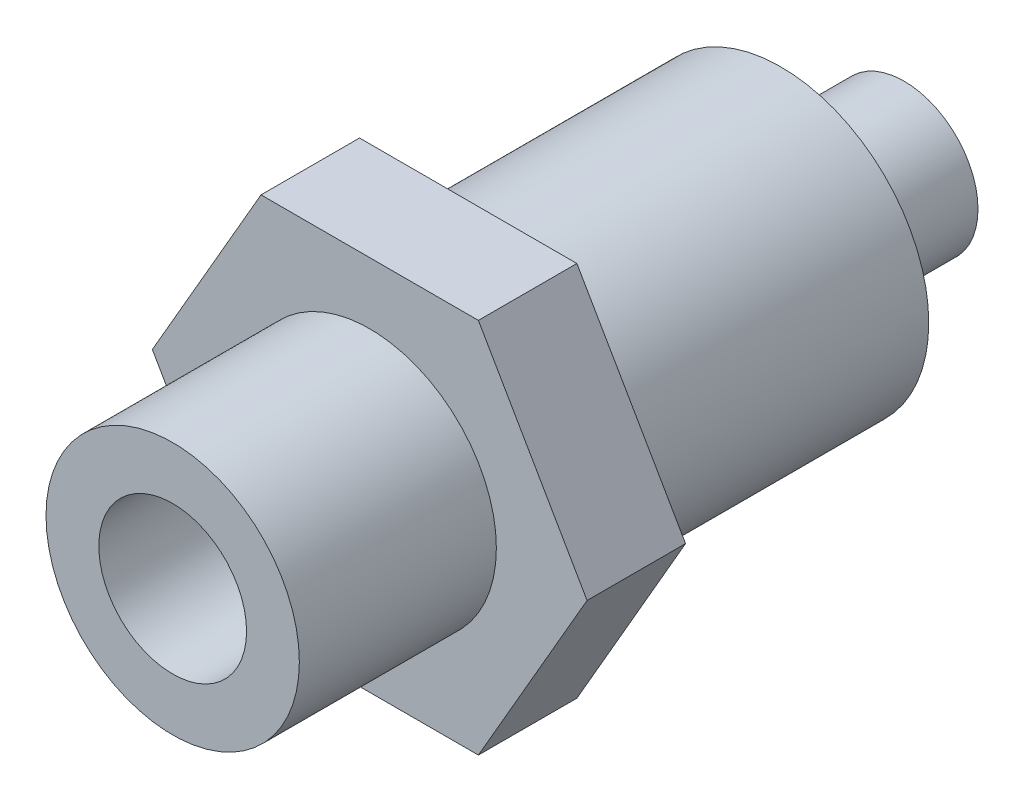
from build123d import *

# Parameters (mm, degrees)
SKETCH1_R           = 5.1435
SKETCH1_R_2         = 3
BOSS_EXTRUDE1_DEPTH = 8
SKETCH1_3_R         = 5.1435
BOSS_EXTRUDE2_DEPTH = 4
BOSS_EXTRUDE3_START = -4
SKETCH1_5_R         = 6
SKETCH1_5_R_2       = 5.1435
SKETCH1_5_R_3       = 3
BOSS_EXTRUDE3_DEPTH = 12.7
BOSS_EXTRUDE4_START = -16.7
SKETCH1_7_R         = 3
BOSS_EXTRUDE4_DEPTH = 5


with BuildPart() as part:
    # Sketch1 → Boss-Extrude1 (new body)
    with BuildSketch(Plane.XY):
        Circle(SKETCH1_R)
        Circle(SKETCH1_R_2, mode=Mode.SUBTRACT)
    extrude(amount=BOSS_EXTRUDE1_DEPTH)


with BuildPart() as body_2:
    # Sketch1_3 → Boss-Extrude2 (new body)
    with BuildSketch(Plane.XY):
        Polygon((8.825953565, 0), (4.412976783, 7.6435), (-4.412976783, 7.6435), (-8.825953565, 0), (-4.412976783, -7.6435), (4.412976783, -7.6435), align=None)
        Circle(SKETCH1_3_R, mode=Mode.SUBTRACT)
    extrude(amount=-BOSS_EXTRUDE2_DEPTH)

    # Sketch1_5 → Boss-Extrude3 (add)
    with BuildSketch(Plane.XY.offset(BOSS_EXTRUDE3_START)):
        Circle(SKETCH1_5_R)
        Circle(SKETCH1_5_R_2, mode=Mode.SUBTRACT)
        Circle(SKETCH1_5_R_2)
        Circle(SKETCH1_5_R_3, mode=Mode.SUBTRACT)
        Circle(SKETCH1_5_R_3)
    extrude(amount=-BOSS_EXTRUDE3_DEPTH)

    # Sketch1_7 → Boss-Extrude4 (add)
    with BuildSketch(Plane.XY.offset(BOSS_EXTRUDE4_START)):
        Circle(SKETCH1_7_R)
    extrude(amount=-BOSS_EXTRUDE4_DEPTH)


solid = Compound([part.part, body_2.part])
